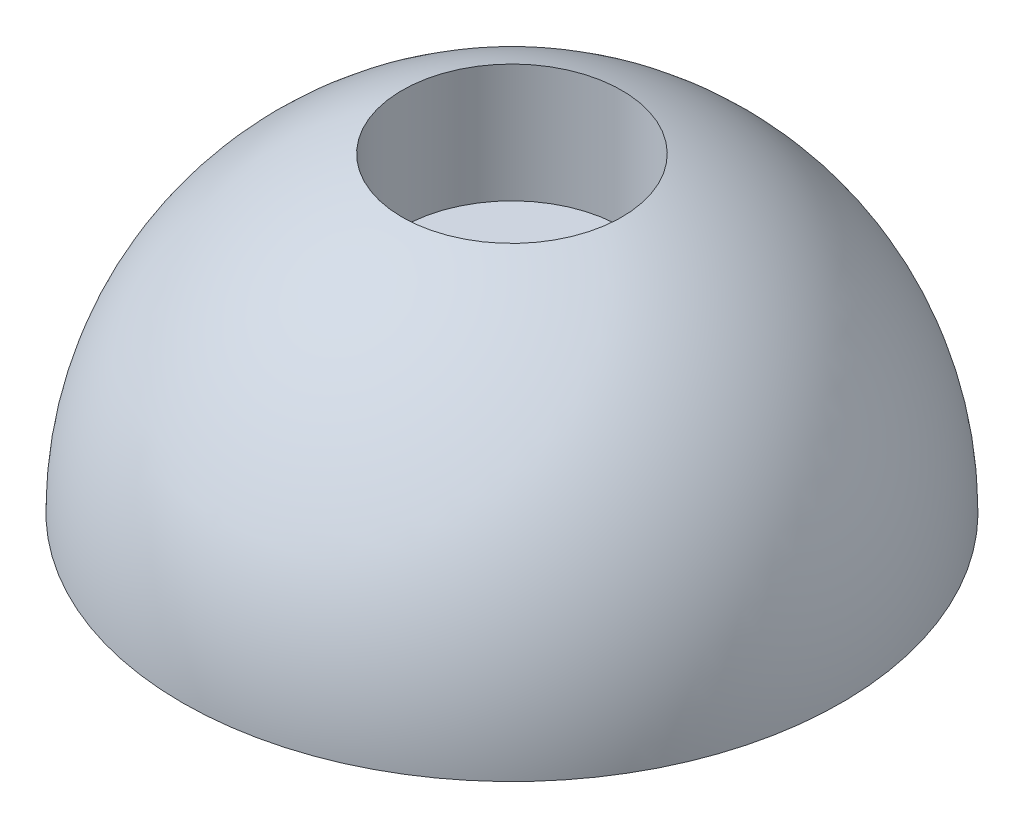
from build123d import *


with BuildPart() as part:
    # Sketch1 → Revolve1 (revolve)
    with BuildSketch(Plane.XY):
        with BuildLine():
            Line((6.35, -2.778125), (6.35, -8.334375))
            Line((6.35, -8.334375), (19.05, -8.334375))
            ThreePointArc((19.05, -8.334375), (15.554259867, 2.664147628), (6.35, 9.626137242))
            Line((6.35, 9.626137242), (6.35, 8.334375))
            Line((6.35, 8.334375), (6.35, 2.778125))
            Line((6.35, 2.778125), (3.302, 2.778125))
            Line((3.302, 2.778125), (3.302, 0))
            Line((3.302, 0), (3.302, -2.778125))
            Line((3.302, -2.778125), (6.35, -2.778125))
        make_face()
    revolve(axis=Axis((0, -2.778125, 0), (0, -1, 0)))


solid = part.part
